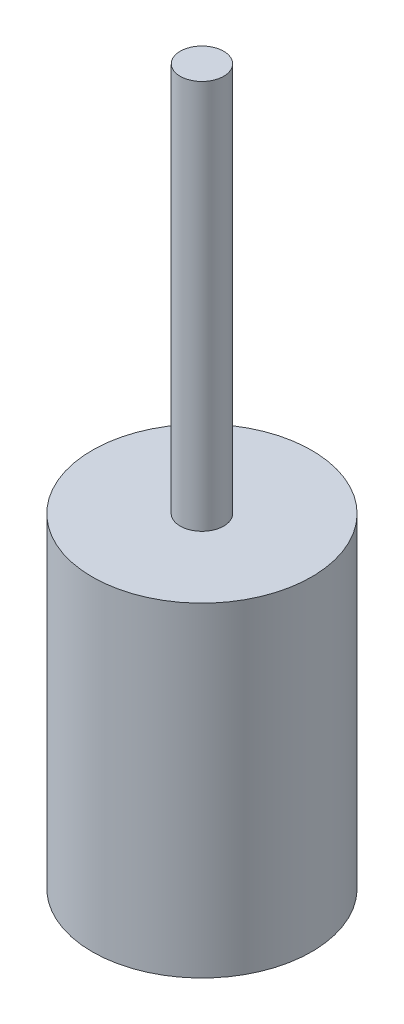
from build123d import *

# Parameters (mm, degrees)
SKETCH1_R           = 21.463
BOSS_EXTRUDE1_DEPTH = 63.5
SKETCH2_R           = 4.25
BOSS_EXTRUDE2_DEPTH = 76.2


with BuildPart() as part:
    # Sketch1 → Boss-Extrude1 (new body)
    with BuildSketch(Plane(origin=(0, 0, 0), x_dir=(1, 0, 0), z_dir=(0, 1, 0))):
        Circle(SKETCH1_R)
    extrude(amount=BOSS_EXTRUDE1_DEPTH)

    # Sketch2 → Boss-Extrude2 (add)
    with BuildSketch(Plane(origin=(0, 63.5, 0), x_dir=(1, 0, 0), z_dir=(0, 1, 0))):
        Circle(SKETCH2_R)
    extrude(amount=BOSS_EXTRUDE2_DEPTH)


solid = part.part
